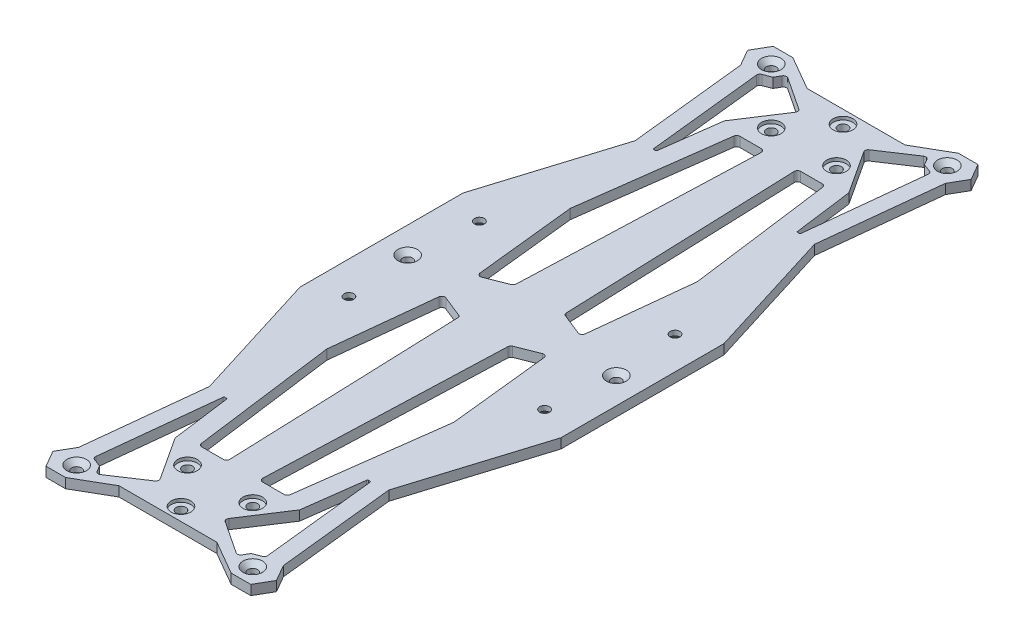
from build123d import *

# Parameters (mm, degrees)
SKETCH_1_W                   = 80
SKETCH_1_H                   = 50
EXTRUDE_1_DEPTH              = 3
SKETCH_3_R                   = 1.5
CUT_EXTRUDE_1_DEPTH          = 3
SKETCH_19_R                  = 1.5
CUT_EXTRUDE_8_DEPTH          = 10
SKETCH_4_R                   = 3
CUT_EXTRUDE_2_DEPTH          = 1
EXTRUDE_2_DEPTH              = 3
SKETCH_8_R                   = 1.5
CUT_EXTRUDE_4_DEPTH          = 3
CUT_EXTRUDE_START            = -4
CUT_EXTRUDE_6_DEPTH          = 5
HOLE_WIZARD_M3_2_D           = 3
HOLE_WIZARD_M3_2_CSINK_D     = 6
HOLE_WIZARD_M3_2_CSINK_ANGLE = 90
HOLE_WIZARD_M3_1_D           = 3
HOLE_WIZARD_M3_1_CSINK_D     = 6
HOLE_WIZARD_M3_1_CSINK_ANGLE = 90
CUT_EXTRUDE_7_DEPTH          = 5
MIRROR_7_COPY_1_SKETCH_R     = 1.5
MIRROR_7_COPY_1_DEPTH        = 3
MIRROR_7_COPY_2_SKETCH_R     = 3
MIRROR_7_COPY_2_DEPTH        = 1
MIRROR_7_COPY_3_DEPTH        = 3
MIRROR_START                 = -4
MIRROR_7_COPY_4_DEPTH        = 5
MIRROR_7_COPY_5_D            = 3
MIRROR_7_COPY_5_CSINK_D      = 6
MIRROR_7_COPY_5_CSINK_ANGLE  = 90
MIRROR_7_COPY_6_D            = 3
MIRROR_7_COPY_6_CSINK_D      = 6
MIRROR_7_COPY_6_CSINK_ANGLE  = 90
MIRROR_7_COPY_7_DEPTH        = 5
FILLET_1_R                   = 1
FILLET_2_R                   = 0.3


with BuildPart() as part:
    # 草图1 → 凸台-拉伸1 (new body)
    with BuildSketch(Plane(origin=(0, 0, 0), x_dir=(1, 0, 0), z_dir=(0, 1, 0))):
        Polygon((-15, -105.5), (-40, -25), (40, -25), (15, -105.5), align=None)
        Rectangle(SKETCH_1_W, SKETCH_1_H)
        Polygon((-15, 105.5), (15, 105.5), (40, 25), (-40, 25), align=None)
    extrude(amount=EXTRUDE_1_DEPTH)

    # 草图3 → 切除-拉伸1 (cut)
    with BuildSketch(Plane(origin=(0, 3, 0), x_dir=(1, 0, 0), z_dir=(0, 1, 0))):
        with Locations((10, 89.5)):
            Circle(SKETCH_3_R)
    cut_extrude_1 = extrude(amount=-CUT_EXTRUDE_1_DEPTH, mode=Mode.SUBTRACT)

    # 草图19 → 切除-拉伸8 (cut)
    with BuildSketch(Plane(origin=(0, 3, 0), x_dir=(1, 0, 0), z_dir=(0, 1, 0))):
        with Locations((0, 101.5)):
            Circle(SKETCH_19_R)
    cut_extrude_8 = extrude(amount=-CUT_EXTRUDE_8_DEPTH, mode=Mode.SUBTRACT)

    # 草图4 → 切除-拉伸2 (cut)
    with BuildSketch(Plane(origin=(0, 3, 0), x_dir=(1, 0, 0), z_dir=(0, 1, 0))):
        with Locations((0, 101.5)):
            Circle(SKETCH_4_R)
        with Locations((10, 89.5)):
            Circle(SKETCH_4_R)
    cut_extrude_2 = extrude(amount=-CUT_EXTRUDE_2_DEPTH, mode=Mode.SUBTRACT)

    # 草图7 → 凸台-拉伸2 (add)
    with BuildSketch(Plane(origin=(0, 3, 0), x_dir=(1, 0, 0), z_dir=(0, 1, 0))):
        Polygon((15, 105.5), (25.392304845, 111.5), (31.392304845, 111.5), (34.279056191, 106.5), (31.392304845, 101.5), (27.5, 65.25), align=None)
    extrude_2 = extrude(amount=-EXTRUDE_2_DEPTH)

    # 草图8 → 切除-拉伸4 (cut)
    with BuildSketch(Plane(origin=(0, 3, 0), x_dir=(1, 0, 0), z_dir=(0, 1, 0))):
        with Locations((27, 106.5)):
            Circle(SKETCH_8_R)
    extrude(amount=-CUT_EXTRUDE_4_DEPTH, mode=Mode.SUBTRACT)

    # 草图9 → 切除-拉伸6 (cut)
    with BuildSketch(Plane(origin=(0, 3, 0), x_dir=(1, 0, 0), z_dir=(0, 1, 0)).offset(CUT_EXTRUDE_START)):
        Polygon((22.528576043, 65.783801312), (26.420880888, 102.033801312), (23.243297221, 103.222190391), (21.66924243, 105.948533263), (16.658152368, 102.627995852), (19.093364206, 84.205898582), (21.528576043, 65.783801312), align=None)
        Polygon((10.313400805, 97.671116845), (19.093364206, 84.205898582), (16.658152368, 102.627995852), (9.970725358, 98.196654308), align=None)
    cut_extrude_6 = extrude(amount=CUT_EXTRUDE_6_DEPTH, mode=Mode.SUBTRACT)

    # M3 六角凹锥坑螺钉的锥形沉头孔2 (through all)
    with Locations(Plane(origin=(0, 0, 0), x_dir=(-1, 0, 0), z_dir=(0, -1, 0))):
        with Locations((30, 20)):
            hole_wizard_m3_2 = CounterSinkHole(HOLE_WIZARD_M3_2_D / 2, HOLE_WIZARD_M3_2_CSINK_D / 2, counter_sink_angle=HOLE_WIZARD_M3_2_CSINK_ANGLE)

    # M3 六角凹锥坑螺钉的锥形沉头孔1 (through all)
    with Locations(Plane(origin=(0, 3, 0), x_dir=(1, 0, 0), z_dir=(0, 1, 0))):
        with Locations((27, 106.5), (32, 0)):
            hole_wizard_m3_1 = CounterSinkHole(HOLE_WIZARD_M3_1_D / 2, HOLE_WIZARD_M3_1_CSINK_D / 2, counter_sink_angle=HOLE_WIZARD_M3_1_CSINK_ANGLE)

    # 镜向5: M3 六角凹锥坑螺钉的锥形沉头孔1 across plane
    add(hole_wizard_m3_1.mirror(Plane(origin=(0, 0, 0), x_dir=(0, 0, 1), z_dir=(1, 0, 0))), mode=Mode.SUBTRACT)

    # 草图18 → 切除-拉伸7 (cut)
    with BuildSketch(Plane(origin=(0, 3, 0), x_dir=(1, 0, 0), z_dir=(0, 1, 0)).offset(CUT_EXTRUDE_START)):
        Polygon((16.001980561, 4.999999521), (19.472317364, 37.320106527), (13.5, 82.5), (5, 82.5), (7.697422824, 8.32087235), align=None)
    cut_extrude_7 = extrude(amount=CUT_EXTRUDE_7_DEPTH, mode=Mode.SUBTRACT)

    # 镜向6: 切除-拉伸1, 切除-拉伸2, 凸台-拉伸2, 切除-拉伸6, M3 六角凹锥坑螺钉的锥形沉头孔2, M3 六角凹锥坑螺钉的锥形沉头孔1, 切除-拉伸7 across plane
    add(cut_extrude_1.mirror(Plane(origin=(0, 0, 0), x_dir=(0, 0, 1), z_dir=(1, 0, 0))), mode=Mode.SUBTRACT)
    add(cut_extrude_2.mirror(Plane(origin=(0, 0, 0), x_dir=(0, 0, 1), z_dir=(1, 0, 0))), mode=Mode.SUBTRACT)
    add(extrude_2.mirror(Plane(origin=(0, 0, 0), x_dir=(0, 0, 1), z_dir=(1, 0, 0))))
    add(cut_extrude_6.mirror(Plane(origin=(0, 0, 0), x_dir=(0, 0, 1), z_dir=(1, 0, 0))), mode=Mode.SUBTRACT)
    add(hole_wizard_m3_2.mirror(Plane(origin=(0, 0, 0), x_dir=(0, 0, 1), z_dir=(1, 0, 0))), mode=Mode.SUBTRACT)
    add(hole_wizard_m3_1.mirror(Plane(origin=(0, 0, 0), x_dir=(0, 0, 1), z_dir=(1, 0, 0))), mode=Mode.SUBTRACT)
    add(cut_extrude_7.mirror(Plane(origin=(0, 0, 0), x_dir=(0, 0, 1), z_dir=(1, 0, 0))), mode=Mode.SUBTRACT)

    # 镜向7: 切除-拉伸8, 切除-拉伸1, 切除-拉伸2, 凸台-拉伸2, 切除-拉伸6, M3 六角凹锥坑螺钉的锥形沉头孔2, M3 六角凹锥坑螺钉的锥形沉头孔1, 切除-拉伸7 across plane
    add(cut_extrude_8.mirror(Plane.XY), mode=Mode.SUBTRACT)
    add(cut_extrude_1.mirror(Plane.XY), mode=Mode.SUBTRACT)
    add(cut_extrude_2.mirror(Plane.XY), mode=Mode.SUBTRACT)
    add(extrude_2.mirror(Plane.XY))
    add(cut_extrude_6.mirror(Plane.XY), mode=Mode.SUBTRACT)
    add(hole_wizard_m3_2.mirror(Plane.XY), mode=Mode.SUBTRACT)
    add(hole_wizard_m3_1.mirror(Plane.XY), mode=Mode.SUBTRACT)
    add(cut_extrude_7.mirror(Plane.XY), mode=Mode.SUBTRACT)

    # 镜向7 copy 1 sketch → 镜向7 copy 1 (cut)
    with BuildSketch(Plane(origin=(0, 3, 0), x_dir=(-1, 0, 0), z_dir=(0, 1, 0))):
        with Locations((10, 89.5)):
            Circle(MIRROR_7_COPY_1_SKETCH_R)
    extrude(amount=-MIRROR_7_COPY_1_DEPTH, mode=Mode.SUBTRACT)

    # 镜向7 copy 2 sketch → 镜向7 copy 2 (cut)
    with BuildSketch(Plane(origin=(0, 3, 0), x_dir=(-1, 0, 0), z_dir=(0, 1, 0))):
        with Locations((0, 101.5)):
            Circle(MIRROR_7_COPY_2_SKETCH_R)
        with Locations((10, 89.5)):
            Circle(MIRROR_7_COPY_2_SKETCH_R)
    extrude(amount=-MIRROR_7_COPY_2_DEPTH, mode=Mode.SUBTRACT)

    # 镜向7 copy 3 sketch → 镜向7 copy 3 (add)
    with BuildSketch(Plane(origin=(0, 3, 0), x_dir=(-1, 0, 0), z_dir=(0, 1, 0))):
        Polygon((15, 105.5), (25.392304845, 111.5), (31.392304845, 111.5), (34.279056191, 106.5), (31.392304845, 101.5), (27.5, 65.25), align=None)
    extrude(amount=-MIRROR_7_COPY_3_DEPTH)

    # 镜向7 copy 4 sketch → 镜向7 copy 4 (cut)
    with BuildSketch(Plane(origin=(0, 3, 0), x_dir=(-1, 0, 0), z_dir=(0, 1, 0)).offset(MIRROR_START)):
        Polygon((22.528576043, 65.783801312), (26.420880888, 102.033801312), (23.243297221, 103.222190391), (21.66924243, 105.948533263), (16.658152368, 102.627995852), (19.093364206, 84.205898582), (21.528576043, 65.783801312), align=None)
        Polygon((10.313400805, 97.671116845), (19.093364206, 84.205898582), (16.658152368, 102.627995852), (9.970725358, 98.196654308), align=None)
    extrude(amount=MIRROR_7_COPY_4_DEPTH, mode=Mode.SUBTRACT)

    # 镜向7 copy 5 (through all)
    with Locations(Plane.XZ):
        with Locations((30, 20)):
            CounterSinkHole(MIRROR_7_COPY_5_D / 2, MIRROR_7_COPY_5_CSINK_D / 2, counter_sink_angle=MIRROR_7_COPY_5_CSINK_ANGLE)

    # 镜向7 copy 6 (through all)
    with Locations(Plane(origin=(0, 3, 0), x_dir=(-1, 0, 0), z_dir=(0, 1, 0))):
        with Locations((27, 106.5), (32, 0)):
            CounterSinkHole(MIRROR_7_COPY_6_D / 2, MIRROR_7_COPY_6_CSINK_D / 2, counter_sink_angle=MIRROR_7_COPY_6_CSINK_ANGLE)

    # 镜向7 copy 7 sketch → 镜向7 copy 7 (cut)
    with BuildSketch(Plane(origin=(0, 3, 0), x_dir=(-1, 0, 0), z_dir=(0, 1, 0)).offset(MIRROR_START)):
        Polygon((16.001980561, 4.999999521), (19.472317364, 37.320106527), (13.5, 82.5), (5, 82.5), (7.697422824, 8.32087235), align=None)
    extrude(amount=MIRROR_7_COPY_7_DEPTH, mode=Mode.SUBTRACT)

    # 圆角1
    fillet_1_edges = [part.edges().sort_by_distance(p)[0] for p in [
        (-26.420880888, 1.5, -102.033801312),
        (-21.66924243, 1.5, -105.948533263),
        (-9.970725358, 1.5, -98.196654308),
        (-13.5, 1.5, -82.5),
        (-5, 1.5, -82.5),
        (-19.472317364, 1.5, -37.320106527),
        (-7.697422824, 1.5, -8.32087235),
        (-16.001980561, 1.5, -4.999999521),
        (13.5, 1.5, -82.5),
        (5, 1.5, -82.5),
        (7.697422824, 1.5, -8.32087235),
        (16.001980561, 1.5, -4.999999521),
        (26.420880888, 1.5, -102.033801312),
        (21.66924243, 1.5, -105.948533263),
        (9.970725358, 1.5, -98.196654308),
        (7.697422824, 1.5, 8.32087235),
        (16.001980561, 1.5, 4.999999521),
        (19.472317364, 1.5, 37.320106527),
        (13.5, 1.5, 82.5),
        (5, 1.5, 82.5),
        (9.970725358, 1.5, 98.196654308),
        (21.66924243, 1.5, 105.948533263),
        (26.420880888, 1.5, 102.033801312),
        (-9.970725358, 1.5, 98.196654308),
        (-21.66924243, 1.5, 105.948533263),
        (-26.420880888, 1.5, 102.033801312),
        (-13.5, 1.5, 82.5),
        (-5, 1.5, 82.5),
        (-19.472317364, 1.5, 37.320106527),
        (-16.001980561, 1.5, 4.999999521),
        (-7.697422824, 1.5, 8.32087235),
    ]]
    fillet(fillet_1_edges, radius=FILLET_1_R)

    # 圆角2
    fillet_2_edges = [part.edges().sort_by_distance(p)[0] for p in [
        (-22.528576043, 1.5, -65.783801312),
        (-21.528576043, 1.5, -65.783801312),
        (22.528576043, 1.5, -65.783801312),
        (21.528576043, 1.5, -65.783801312),
        (21.528576043, 1.5, 65.783801312),
        (22.528576043, 1.5, 65.783801312),
        (-21.528576043, 1.5, 65.783801312),
        (-22.528576043, 1.5, 65.783801312),
    ]]
    fillet(fillet_2_edges, radius=FILLET_2_R)


solid = part.part
